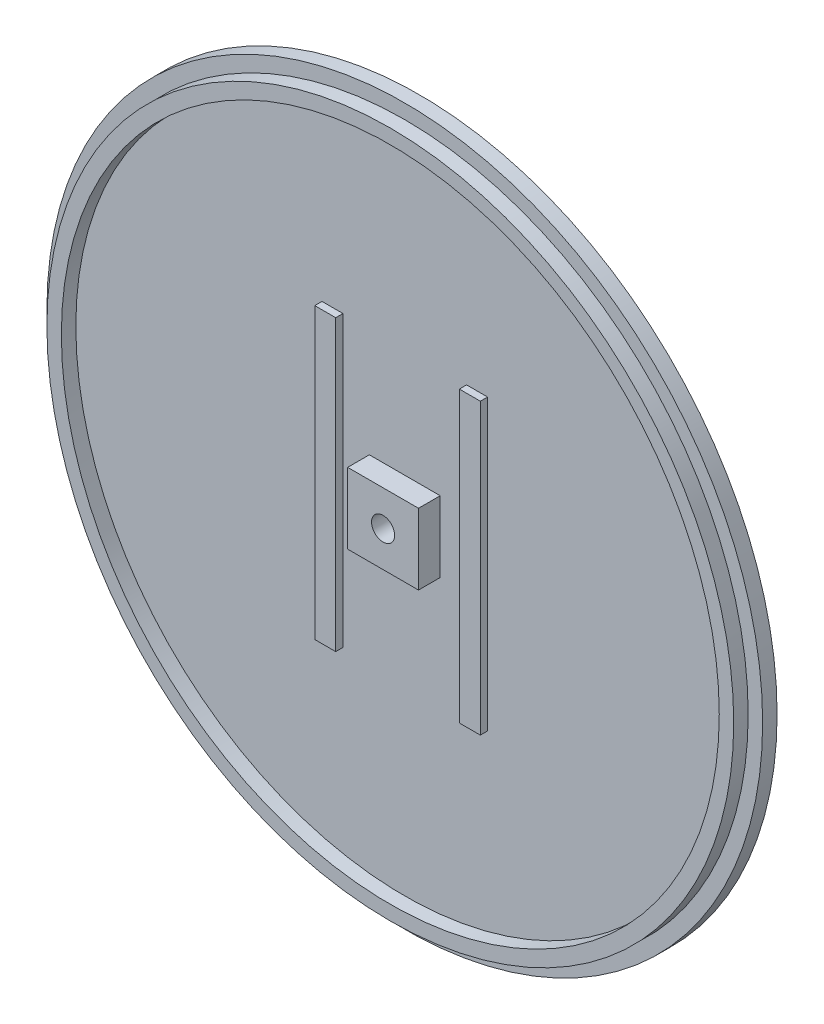
from build123d import *

# Parameters (mm, degrees)
SKETCH1_R                                         = 49.5
MAIN_DEPTH                                        = 2
SKETCH2_W                                         = 2.9
SKETCH2_H                                         = 40
SKETCH2_W_2                                       = 2.90180049
MAKERBEAMFIX_DEPTH                                = 1
SKETCH3_W                                         = 9.8
SKETCH3_H                                         = 9.8
CENTRALFIX_DEPTH                                  = 3
CSK_FOR_M2_5_FLAT_HEAD_MACHINE_SCREW1_D           = 3.2
CSK_FOR_M2_5_FLAT_HEAD_MACHINE_SCREW1_CSINK_D     = 6
CSK_FOR_M2_5_FLAT_HEAD_MACHINE_SCREW1_CSINK_ANGLE = 90
SKETCH6_R                                         = 47.5
SKETCH6_R_2                                       = 45.5
CIRCLESUPPORT_DEPTH                               = 2


with BuildPart() as part:
    # Sketch1 → Main (new body)
    with BuildSketch(Plane.XY):
        Circle(SKETCH1_R)
    extrude(amount=MAIN_DEPTH)

    # Sketch2 → MakerBeamFix (add)
    with BuildSketch(Plane.XY.offset(2)):
        with Locations((-10, 0)):
            Rectangle(SKETCH2_W, SKETCH2_H)
        with Locations((10, 0)):
            Rectangle(SKETCH2_W_2, SKETCH2_H)
    extrude(amount=MAKERBEAMFIX_DEPTH)

    # Sketch3 → CentralFix (add)
    with BuildSketch(Plane.XY.offset(2)):
        Rectangle(SKETCH3_W, SKETCH3_H)
    extrude(amount=CENTRALFIX_DEPTH)

    # CSK for M2.5 Flat Head Machine Screw1 (through all)
    with Locations(Plane(origin=(0, 0, 0), x_dir=(-1, 0, 0), z_dir=(0, 0, -1))):
        with Locations((0, 0)):
            CounterSinkHole(CSK_FOR_M2_5_FLAT_HEAD_MACHINE_SCREW1_D / 2, CSK_FOR_M2_5_FLAT_HEAD_MACHINE_SCREW1_CSINK_D / 2, counter_sink_angle=CSK_FOR_M2_5_FLAT_HEAD_MACHINE_SCREW1_CSINK_ANGLE)

    # Sketch6 → CircleSupport (add)
    with BuildSketch(Plane.XY.offset(2)):
        Circle(SKETCH6_R)
        Circle(SKETCH6_R_2, mode=Mode.SUBTRACT)
    extrude(amount=CIRCLESUPPORT_DEPTH)


solid = part.part
